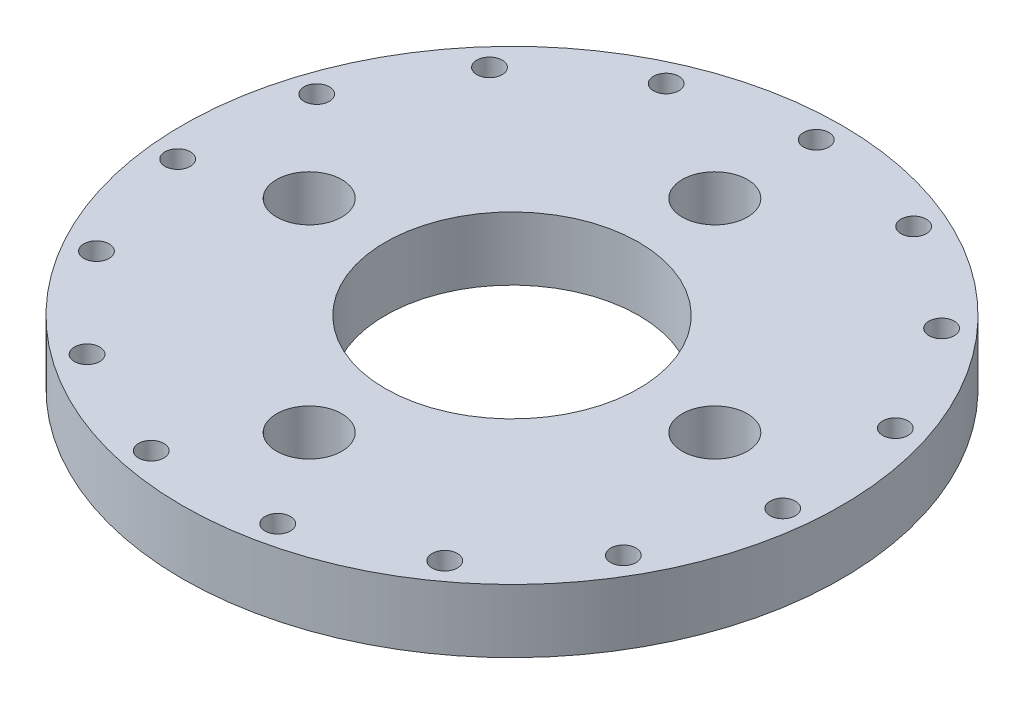
from build123d import *

# Parameters (mm, degrees)
SKETCH1_R           = 16.51
SKETCH1_R_2         = 6.35
BOSS_EXTRUDE1_DEPTH = 3.175
CIRPATTERN1_COUNT   = 4
SKETCH4_R           = 0.635
CUT_EXTRUDE1_DEPTH  = 3.175
CIRPATTERN2_COUNT   = 15


with BuildPart() as part:
    # Sketch1 → Boss-Extrude1 (new body)
    with BuildSketch(Plane(origin=(0, 0, 0), x_dir=(1, 0, 0), z_dir=(0, 1, 0))):
        Circle(SKETCH1_R)
        Circle(SKETCH1_R_2, mode=Mode.SUBTRACT)
    extrude(amount=BOSS_EXTRUDE1_DEPTH)

    # Sketch2 → #4 Clearance Hole1 (revolve, cut)
    with BuildSketch(Plane(origin=(0, 3.175, -10.16), x_dir=(0, 0, 1), z_dir=(1, 0, 0))):
        Polygon((0, 0), (0, 11.140574487), (1.63195, 10.16), (1.63195, 0), align=None)
    f_4_clearance_hole1 = revolve(axis=Axis((0, 9.525, -10.16), (0, -1, 0)), mode=Mode.SUBTRACT)

    # CirPattern1: #4 Clearance Hole1 ×4 about axis
    cirpattern1_axis = Axis((0, 0, 0), (0, 1, 0))
    for i in range(1, CIRPATTERN1_COUNT):
        add(f_4_clearance_hole1.rotate(cirpattern1_axis, i * 360 / CIRPATTERN1_COUNT), mode=Mode.SUBTRACT)

    # Sketch4 → Cut-Extrude1 (cut)
    with BuildSketch(Plane(origin=(0, 3.175, 0), x_dir=(1, 0, 0), z_dir=(0, 1, 0))):
        with Locations((0, 15.24)):
            Circle(SKETCH4_R)
    cut_extrude1 = extrude(amount=-CUT_EXTRUDE1_DEPTH, mode=Mode.SUBTRACT)

    # CirPattern2: Cut-Extrude1 ×15 about axis
    cirpattern2_axis = Axis((0, 0, 0), (0, 1, 0))
    for i in range(1, CIRPATTERN2_COUNT):
        add(cut_extrude1.rotate(cirpattern2_axis, i * 360 / CIRPATTERN2_COUNT), mode=Mode.SUBTRACT)


solid = part.part
